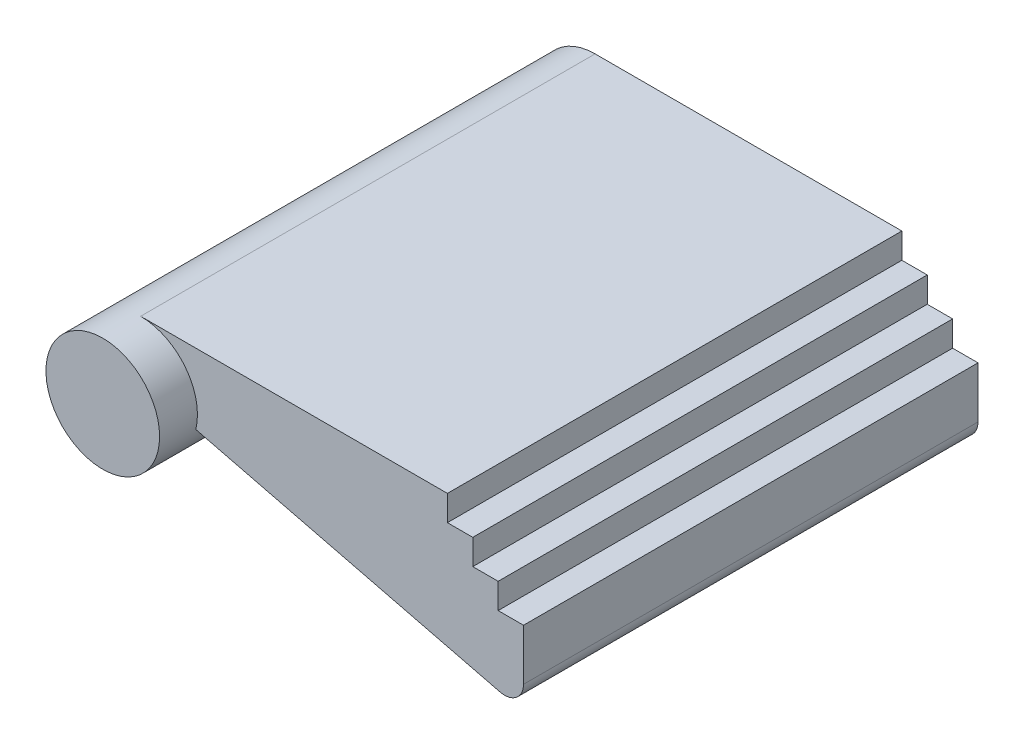
from build123d import *

# Parameters (mm, degrees)
SKETCH_1_R      = 1.5
EXTRUDE_1_DEPTH = 13
EXTRUDE_2_DEPTH = 12
FILLET_1_R      = 0.5


with BuildPart() as part:
    # 草图1 → 凸台-拉伸1 (new body)
    with BuildSketch(Plane.XY):
        Circle(SKETCH_1_R)
    extrude(amount=EXTRUDE_1_DEPTH)

    # 草图2 → 凸台-拉伸2 (add)
    with BuildSketch(Plane.XY):
        Polygon((0, 1.5), (8.1, 1.5), (8.1, 0.83), (8.77, 0.83), (8.77, 0.16), (9.44, 0.16), (9.44, -0.51), (10.11, -0.51), (10.11, -2.5), (0, 0), align=None)
    extrude(amount=EXTRUDE_2_DEPTH)

    # 圆角1
    fillet_1_edges = [part.edges().sort_by_distance(p)[0] for p in [
        (10.11, -2.5, 6),
    ]]
    fillet(fillet_1_edges, radius=FILLET_1_R)


solid = part.part
